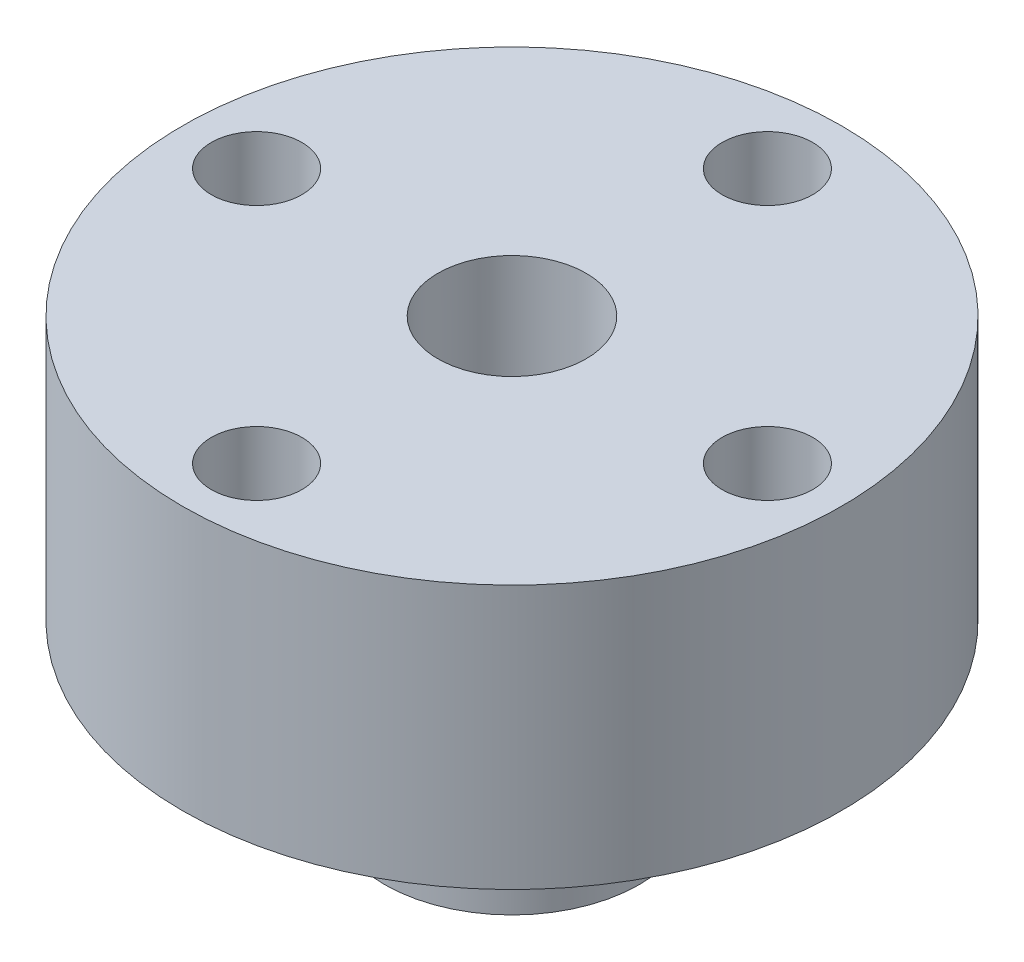
from build123d import *

# Parameters (mm, degrees)
SKETCH1_R                = 3.875
BOSS_EXTRUDE1_DEPTH      = 9
BOSS_EXTRUDE1_DEPTH_BACK = 4
SKETCH2_R                = 5.4
BOSS_EXTRUDE2_DEPTH      = 9
SKETCH7_R                = 10
BOSS_EXTRUDE4_DEPTH      = 8
SKETCH8_R                = 2.25
CUT_EXTRUDE4_DEPTH       = 1
CUT_EXTRUDE4_DEPTH_BACK  = 14
CUT_EXTRUDE2_START       = -9
SKETCH3_R                = 1.375
CUT_EXTRUDE2_DEPTH       = 10
CIRPATTERN2_COUNT        = 4


with BuildPart() as part:
    # Sketch1 → Boss-Extrude1 (new body, two sides)
    with BuildSketch(Plane(origin=(0, 0, 0), x_dir=(1, 0, 0), z_dir=(0, 1, 0))) as boss_extrude1_sk:
        Circle(SKETCH1_R)
    extrude(amount=BOSS_EXTRUDE1_DEPTH)
    extrude(boss_extrude1_sk.sketch, amount=-BOSS_EXTRUDE1_DEPTH_BACK)

    # Sketch2 → Boss-Extrude2 (add)
    with BuildSketch(Plane(origin=(0, 0, 0), x_dir=(1, 0, 0), z_dir=(0, 1, 0))):
        Circle(SKETCH2_R)
    extrude(amount=BOSS_EXTRUDE2_DEPTH)

    # Sketch7 → Boss-Extrude4 (add)
    with BuildSketch(Plane(origin=(0, 9, 0), x_dir=(1, 0, 0), z_dir=(0, 1, 0))):
        Circle(SKETCH7_R)
    extrude(amount=-BOSS_EXTRUDE4_DEPTH)

    # Sketch8 → Cut-Extrude4 (cut, two sides)
    with BuildSketch(Plane.XZ.offset(4)) as cut_extrude4_sk:
        Circle(SKETCH8_R)
    extrude(amount=CUT_EXTRUDE4_DEPTH, mode=Mode.SUBTRACT)
    extrude(cut_extrude4_sk.sketch, amount=-CUT_EXTRUDE4_DEPTH_BACK, mode=Mode.SUBTRACT)

    # Sketch3 → Cut-Extrude2 (cut)
    with BuildSketch(Plane(origin=(0, 9, 0), x_dir=(1, 0, 0), z_dir=(0, 1, 0)).offset(CUT_EXTRUDE2_START)):
        with Locations((-7.75, 0)):
            Circle(SKETCH3_R)
    cut_extrude2 = extrude(amount=CUT_EXTRUDE2_DEPTH, mode=Mode.SUBTRACT)

    # CirPattern2: Cut-Extrude2 ×4 about axis
    cirpattern2_axis = Axis((0, 0, 0), (0, 1, 0))
    for i in range(1, CIRPATTERN2_COUNT):
        add(cut_extrude2.rotate(cirpattern2_axis, i * 360 / CIRPATTERN2_COUNT), mode=Mode.SUBTRACT)


solid = part.part
